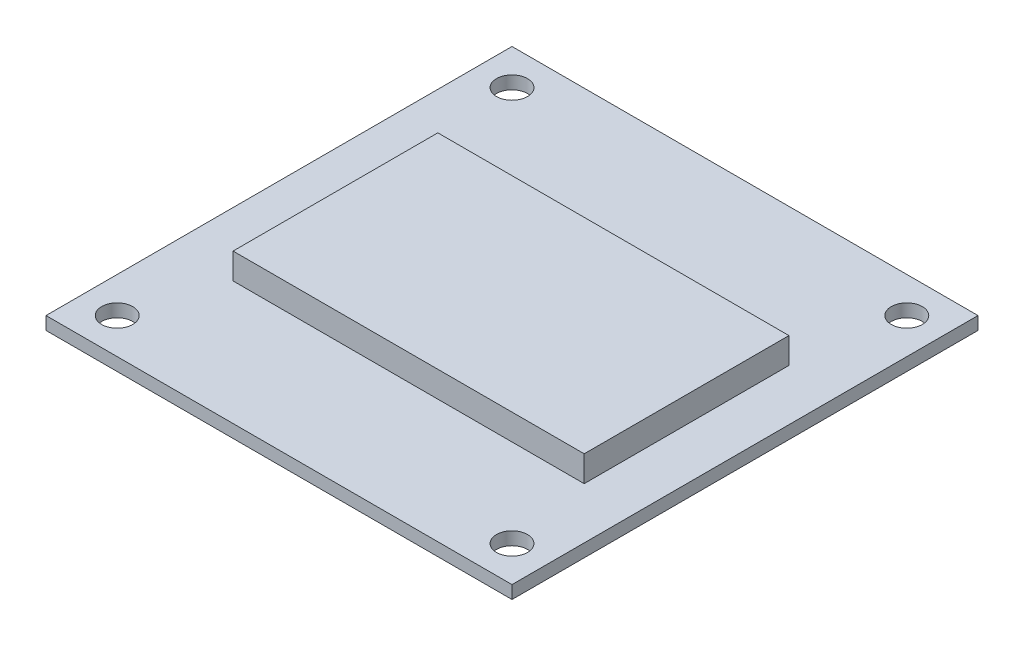
from build123d import *

# Parameters (mm, degrees)
ESQUISSE1_W        = 36
ESQUISSE1_H        = 36
BOSS_EXTRU_1_DEPTH = 1
D_GAGEMENT_M21_D   = 2.4
ESQUISSE4_W        = 27.125417606
ESQUISSE4_H        = 15.817725109
BOSS_EXTRU_2_DEPTH = 2


with BuildPart() as part:
    # Esquisse1 → Boss.-Extru.1 (new body)
    with BuildSketch(Plane(origin=(0, 0, 0), x_dir=(1, 0, 0), z_dir=(0, 1, 0))):
        with Locations((18, 18)):
            Rectangle(ESQUISSE1_W, ESQUISSE1_H)
    extrude(amount=BOSS_EXTRU_1_DEPTH)

    # Dégagement M21 (through all)
    with Locations(Plane(origin=(0, 1, 0), x_dir=(1, 0, 0), z_dir=(0, 1, 0))):
        with Locations((2.75, 2.75), (2.75, 33.25), (33.25, 33.25), (33.25, 2.75)):
            Hole(D_GAGEMENT_M21_D / 2)

    # Esquisse4 → Boss.-Extru.2 (add)
    with BuildSketch(Plane(origin=(0, 1, 0), x_dir=(1, 0, 0), z_dir=(0, 1, 0))):
        with Locations((18.47521777, 17.448351925)):
            Rectangle(ESQUISSE4_W, ESQUISSE4_H)
    extrude(amount=BOSS_EXTRU_2_DEPTH)


solid = part.part
